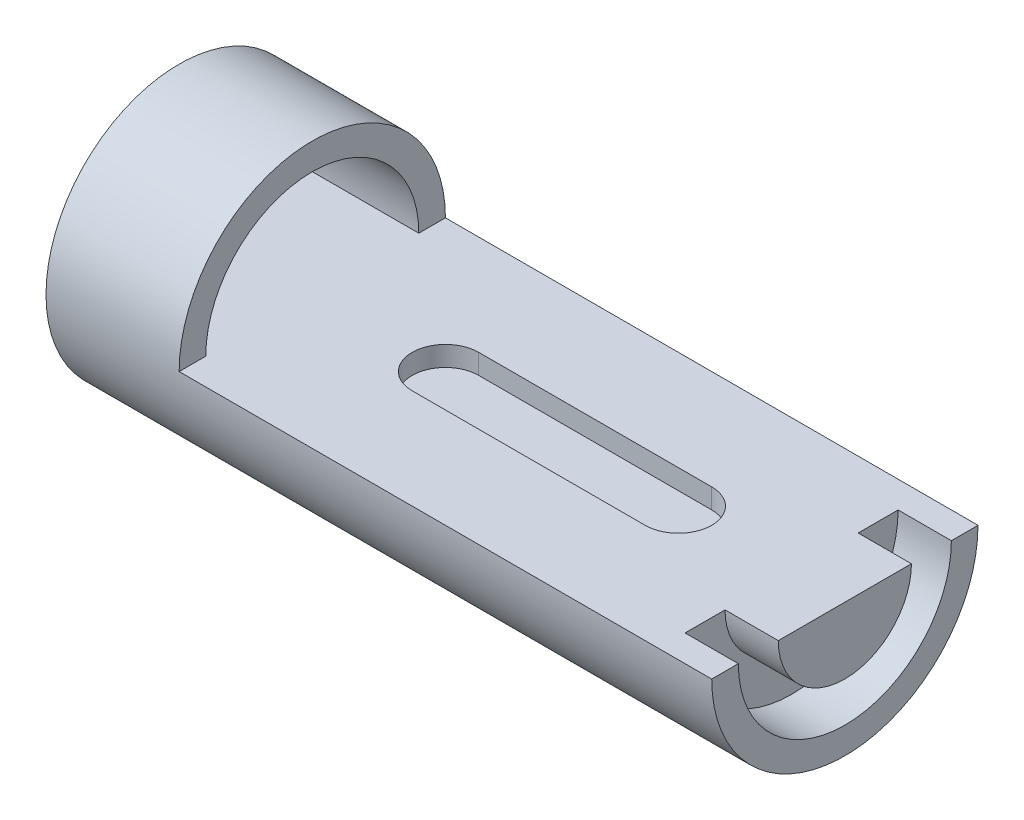
from build123d import *

# Parameters (mm, degrees)
CUT_EXTRUDE1_DEPTH      = 3000
CUT_EXTRUDE3_DEPTH      = 100000
SKETCH6_W               = 80000
SKETCH6_H               = 20000
CUT_EXTRUDE4_DEPTH      = 25001
CUT_EXTRUDE4_DEPTH_BACK = 15001


with BuildPart() as part:
    # Sketch1 → Revolve4 (revolve)
    with BuildSketch(Plane(origin=(0, 0, 0), x_dir=(1, 0, 0), z_dir=(0, 1, 0))):
        Polygon((0, 0), (100000, 0), (100000, -4000), (92000, -4000), (92000, -10000), (100000, -10000), (100000, -20000), (80000, -20000), (0, -20000), align=None)
    revolve(axis=Axis((80000, 0, 20000), (1, 0, 0)))

    # Sketch3 → Cut-Extrude1 (cut)
    with BuildSketch(Plane(origin=(0, 0, 0), x_dir=(1, 0, 0), z_dir=(0, 1, 0))):
        with BuildLine():
            Line((40000, -15000), (75000, -15000))
            ThreePointArc((75000, -15000), (80000, -20000), (75000, -25000))
            Line((75000, -25000), (40000, -25000))
            ThreePointArc((40000, -25000), (35000, -20000), (40000, -15000))
        make_face()
    extrude(amount=-CUT_EXTRUDE1_DEPTH, mode=Mode.SUBTRACT)

    # Sketch5 → Cut-Extrude3 (cut)
    with BuildSketch(Plane.ZY):
        with BuildLine():
            Line((4000, 0), (36000, 0))
            ThreePointArc((36000, 0), (20000, 16000), (4000, 0))
        make_face()
    extrude(amount=-CUT_EXTRUDE3_DEPTH, mode=Mode.SUBTRACT)

    # Sketch6 → Cut-Extrude4 (cut, two sides)
    with BuildSketch(Plane(origin=(0, 0, 25000), x_dir=(-1, 0, 0), z_dir=(0, 0, -1))) as cut_extrude4_sk:
        with Locations((-60000, 10000)):
            Rectangle(SKETCH6_W, SKETCH6_H)
    extrude(amount=CUT_EXTRUDE4_DEPTH, mode=Mode.SUBTRACT)
    extrude(cut_extrude4_sk.sketch, amount=-CUT_EXTRUDE4_DEPTH_BACK, mode=Mode.SUBTRACT)


solid = part.part
